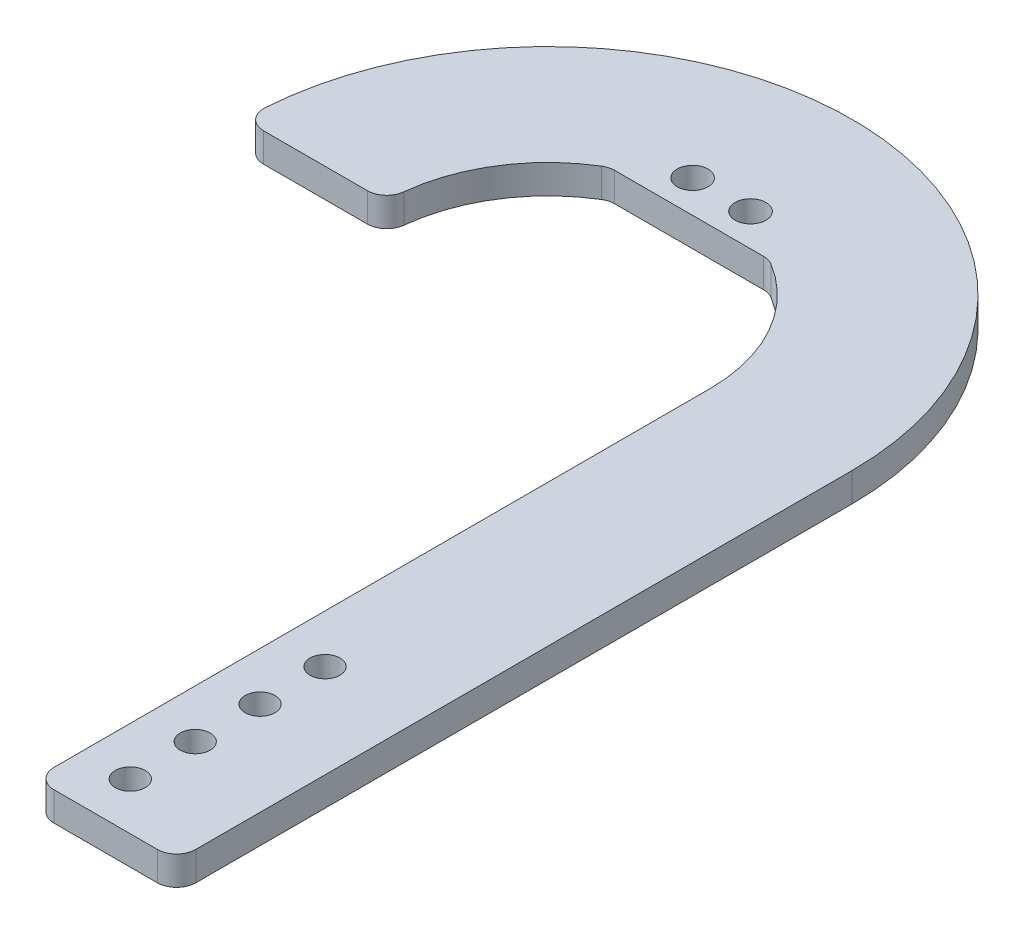
from build123d import *

# Parameters (mm, degrees)
SKETCH2_R           = 1.55
BOSS_EXTRUDE1_DEPTH = 3
FILLET1_R           = 2


with BuildPart() as part:
    # Sketch2 → Boss-Extrude1 (new body)
    with BuildSketch(Plane(origin=(0, 0, 0), x_dir=(1, 0, 0), z_dir=(0, 1, 0))):
        with BuildLine():
            Line((16.8134, 0), (16.8134, -70))
            Line((16.8134, -70), (26.8134, -70))
            Line((26.8134, -70), (26.8134, -40))
            Line((26.8134, -40), (31.5228, 0))
            ThreePointArc((31.5228, 0), (0, 31.5228), (-31.5228, 0))
            Line((-31.5228, 0), (-16.8134, 0))
            ThreePointArc((-16.8134, 0), (-14.522227787, 8.473211887), (-8.27315, 14.63712433))
            ThreePointArc((-8.27315, 14.63712433), (-5.923049404, 15.735561805), (-3.431948685, 16.459409096))
            ThreePointArc((-3.431948685, 16.459409096), (-3.966664912, 19.274974097), (-1.4, 18))
            ThreePointArc((-1.4, 18), (-1.583454565, 17.256092055), (-2.091748789, 16.682775745))
            ThreePointArc((-2.091748789, 16.682775745), (0, 16.8134), (2.091748789, 16.682775745))
            ThreePointArc((2.091748789, 16.682775745), (2.256092055, 19.416545435), (4.6, 18))
            ThreePointArc((4.6, 18), (4.274974097, 17.033335088), (3.431948685, 16.459409096))
            ThreePointArc((3.431948685, 16.459409096), (5.923049404, 15.735561805), (8.27315, 14.63712433))
            ThreePointArc((8.27315, 14.63712433), (14.522227787, 8.473211887), (16.8134, 0))
        make_face()
        with Locations((21.8134, -65.0887)):
            Circle(SKETCH2_R, mode=Mode.SUBTRACT)
        with Locations((21.8134, -58.3629)):
            Circle(SKETCH2_R, mode=Mode.SUBTRACT)
        with Locations((21.8134, -51.6371)):
            Circle(SKETCH2_R, mode=Mode.SUBTRACT)
        with Locations((21.8134, -44.9113)):
            Circle(SKETCH2_R, mode=Mode.SUBTRACT)
        with BuildLine():
            Line((-8.27315, 14.63712433), (8.27315, 14.63712433))
            ThreePointArc((8.27315, 14.63712433), (5.923049404, 15.735561805), (3.431948685, 16.459409096))
            ThreePointArc((3.431948685, 16.459409096), (2.73696162, 16.421769722), (2.091748789, 16.682775745))
            ThreePointArc((2.091748789, 16.682775745), (0, 16.8134), (-2.091748789, 16.682775745))
            ThreePointArc((-2.091748789, 16.682775745), (-2.73696162, 16.421769722), (-3.431948685, 16.459409096))
            ThreePointArc((-3.431948685, 16.459409096), (-5.923049404, 15.735561805), (-8.27315, 14.63712433))
        make_face()
        Polygon((31.5228, -70), (26.8134, -70), (26.8134, -40), (31.5228, 0), align=None)
    extrude(amount=BOSS_EXTRUDE1_DEPTH)

    # Fillet1
    fillet1_edges = [part.edges().sort_by_distance(p)[0] for p in [
        (-16.8134, 1.5, 0),
        (-31.5228, 1.5, 0),
        (31.5228, 1.5, 70),
        (16.8134, 1.5, 70),
        (8.27315, 1.5, -14.63712433),
        (-8.27315, 1.5, -14.63712433),
    ]]
    fillet(fillet1_edges, radius=FILLET1_R)


solid = part.part
